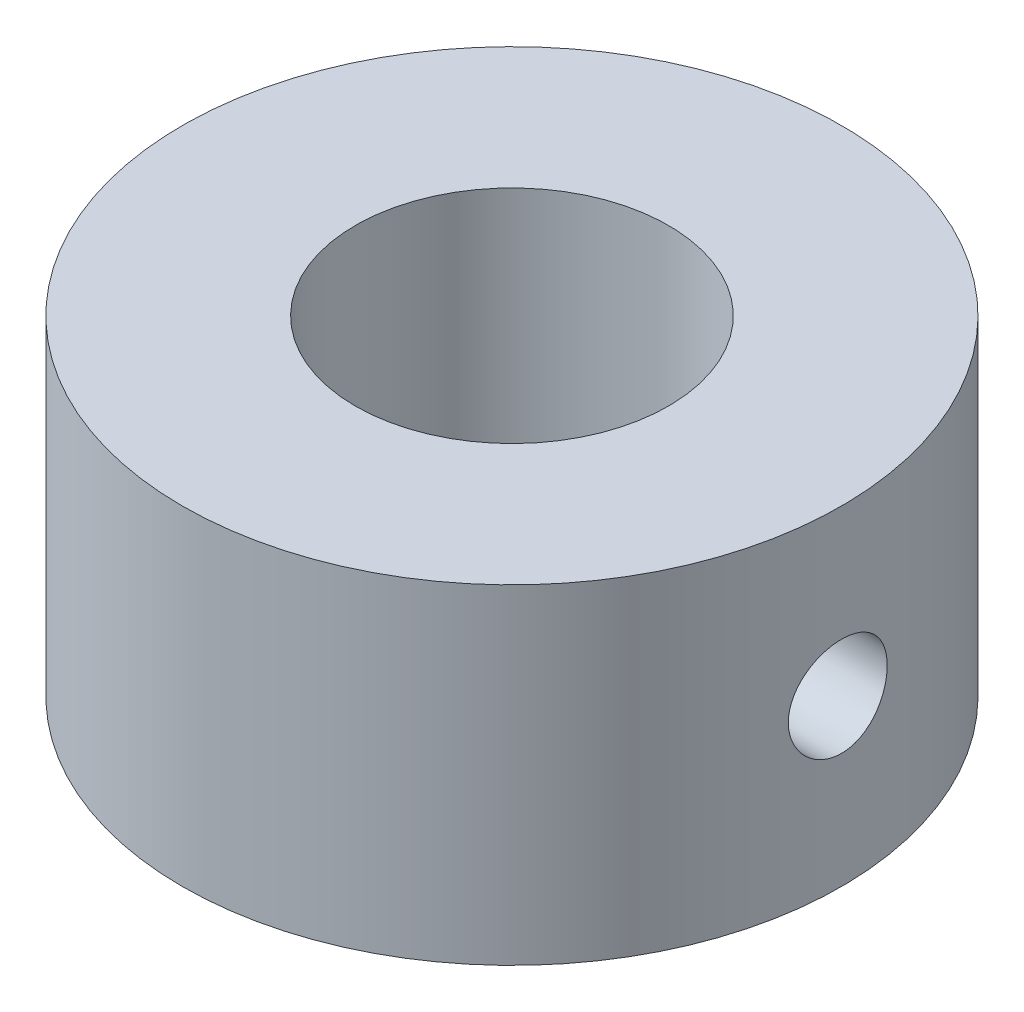
from build123d import *

# Parameters (mm, degrees)
SKETCH1_R           = 10
SKETCH1_R_2         = 4.75
BOSS_EXTRUDE1_DEPTH = 10
CUT_EXTRUDE1_DEPTH  = 10


with BuildPart() as part:
    # Sketch1 → Boss-Extrude1 (new body)
    with BuildSketch(Plane(origin=(0, 0, 0), x_dir=(1, 0, 0), z_dir=(0, 1, 0))):
        Circle(SKETCH1_R)
        Circle(SKETCH1_R_2, mode=Mode.SUBTRACT)
    extrude(amount=BOSS_EXTRUDE1_DEPTH)

    # Sketch2 → Cut-Extrude1 (cut)
    with BuildSketch(Plane(origin=(10, 0, 0), x_dir=(0, 0, -1), z_dir=(1, 0, 0))):
        with BuildLine():
            ThreePointArc((0, 6.5), (-1.5, 5), (0, 3.5))
            Line((0, 3.5), (0, 6.5))
        make_face()
        with BuildLine():
            Line((0, 6.5), (0, 3.5))
            ThreePointArc((0, 3.5), (1.060660172, 3.939339828), (1.5, 5))
            ThreePointArc((1.5, 5), (1.060660172, 6.060660172), (0, 6.5))
        make_face()
    extrude(amount=-CUT_EXTRUDE1_DEPTH, mode=Mode.SUBTRACT)


solid = part.part
